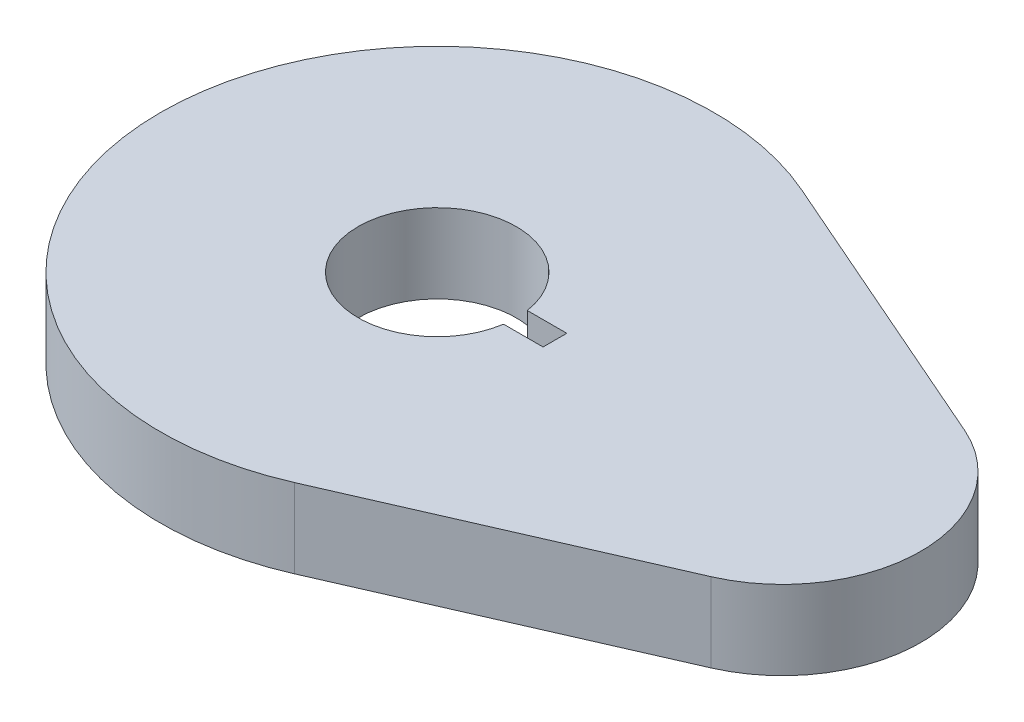
from build123d import *

# Parameters (mm, degrees)
BOSS_EXTRUDE1_DEPTH = 10


with BuildPart() as part:
    # Sketch1 → Boss-Extrude1 (new body)
    with BuildSketch(Plane(origin=(0, 0, 0), x_dir=(1, 0, 0), z_dir=(0, 1, 0))):
        with BuildLine():
            ThreePointArc((14.028659191, 32.065506722), (-35, 0), (14.028659191, -32.065506722))
            Line((14.028659191, -32.065506722), (50.674952587, -16.032753361))
            ThreePointArc((50.674952587, -16.032753361), (61.160622991, 0), (50.674952587, 16.032753361))
            Line((50.674952587, 16.032753361), (14.028659191, 32.065506722))
        make_face()
        with BuildLine():
            Line((9.886859967, 1.5), (14.886859967, 1.5))
            Line((14.886859967, 1.5), (14.886859967, -1.5))
            Line((14.886859967, -1.5), (9.886859967, -1.5))
            ThreePointArc((9.886859967, -1.5), (-10, 0), (9.886859967, 1.5))
        make_face(mode=Mode.SUBTRACT)
    extrude(amount=BOSS_EXTRUDE1_DEPTH)


solid = part.part
